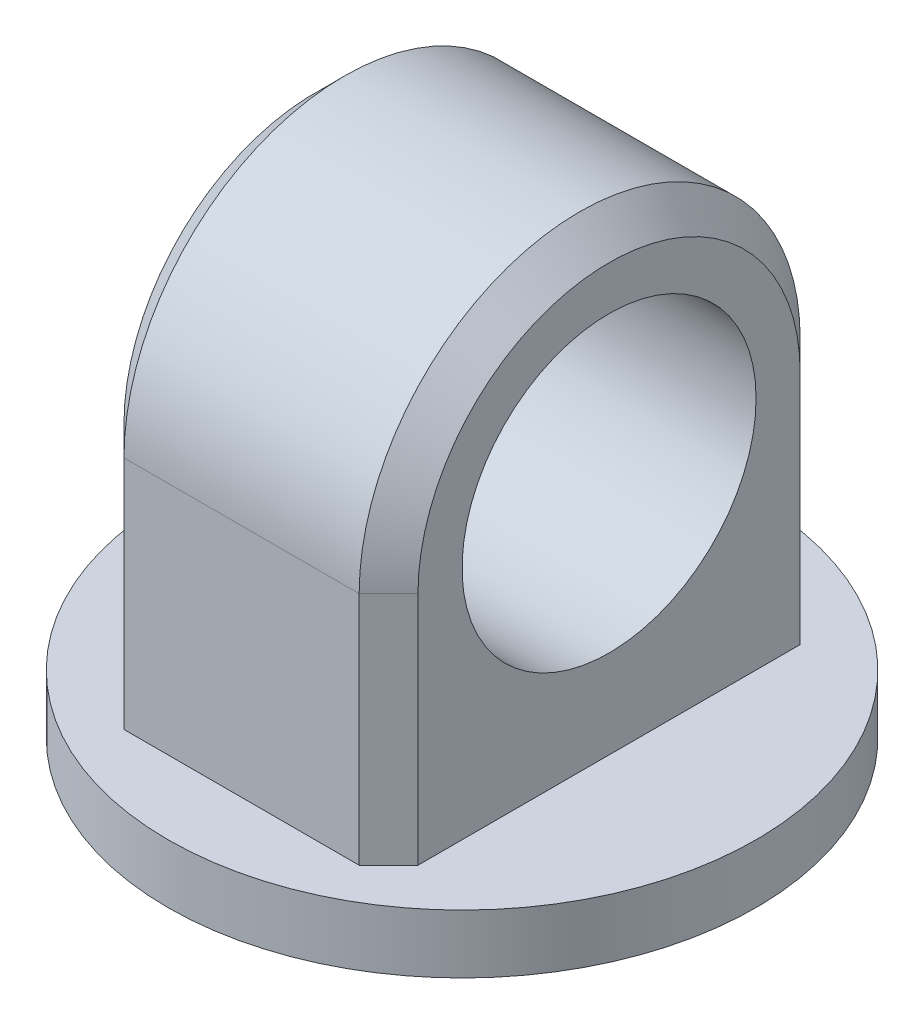
from build123d import *

# Parameters (mm, degrees)
SKETCH1_R           = 50
BOSS_EXTRUDE1_DEPTH = 10
SKETCH2_W           = 50
SKETCH2_H           = 75
BOSS_EXTRUDE2_DEPTH = 80
SKETCH3_R           = 25
CUT_EXTRUDE4_DEPTH  = 76
CUT_EXTRUDE5_DEPTH  = 76
CHAMFER1_SIZE       = 5


with BuildPart() as part:
    # Sketch1 → Boss-Extrude1 (new body)
    with BuildSketch(Plane(origin=(0, 0, 0), x_dir=(1, 0, 0), z_dir=(0, 1, 0))):
        Circle(SKETCH1_R)
    extrude(amount=BOSS_EXTRUDE1_DEPTH)

    # Sketch2 → Boss-Extrude2 (add)
    with BuildSketch(Plane(origin=(0, 10, 0), x_dir=(1, 0, 0), z_dir=(0, 1, 0))):
        Rectangle(SKETCH2_W, SKETCH2_H)
    extrude(amount=BOSS_EXTRUDE2_DEPTH)

    # Sketch3 → Cut-Extrude4 (cut, through all)
    with BuildSketch(Plane(origin=(25, 0, 0), x_dir=(0, 0, -1), z_dir=(1, 0, 0))):
        with Locations((0, 50)):
            Circle(SKETCH3_R)
    extrude(amount=-CUT_EXTRUDE4_DEPTH, mode=Mode.SUBTRACT)

    # Sketch4 → Cut-Extrude5 (cut, through all)
    with BuildSketch(Plane(origin=(25, 0, 0), x_dir=(0, 0, -1), z_dir=(1, 0, 0))):
        with BuildLine():
            Line((-37.5, 50), (-37.5, 90))
            Line((-37.5, 90), (37.5, 90))
            Line((37.5, 90), (37.5, 50))
            ThreePointArc((37.5, 50), (0, 87.5), (-37.5, 50))
        make_face()
    extrude(amount=-CUT_EXTRUDE5_DEPTH, mode=Mode.SUBTRACT)

    # Chamfer1
    chamfer1_edges = [part.edges().sort_by_distance(p)[0] for p in [
        (25, 30, 37.5),
        (-25, 30, 37.5),
        (-25, 30, -37.5),
        (25, 30, -37.5),
        (-25, 87.5, 0),
        (25, 87.5, 0),
    ]]
    chamfer(chamfer1_edges, length=CHAMFER1_SIZE)


solid = part.part
